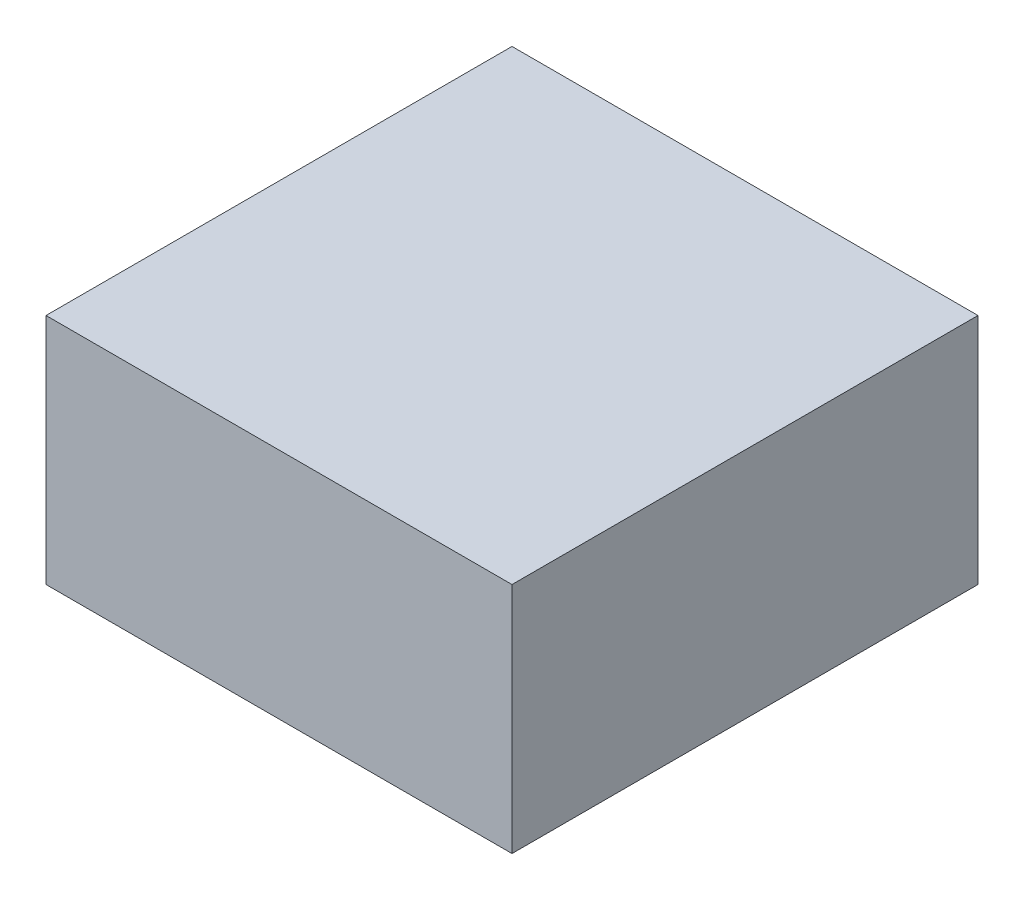
from build123d import *

# Parameters (mm, degrees)
SKETCH1_W      = 500
SKETCH1_H      = 500
EXTRUDE1_DEPTH = 125


with BuildPart() as part:
    # Sketch1 → Extrude1 (new body, symmetric)
    with BuildSketch(Plane(origin=(0, 0, 0), x_dir=(1, 0, 0), z_dir=(0, 1, 0))):
        Rectangle(SKETCH1_W, SKETCH1_H)
    extrude(amount=EXTRUDE1_DEPTH, both=True)


solid = part.part
